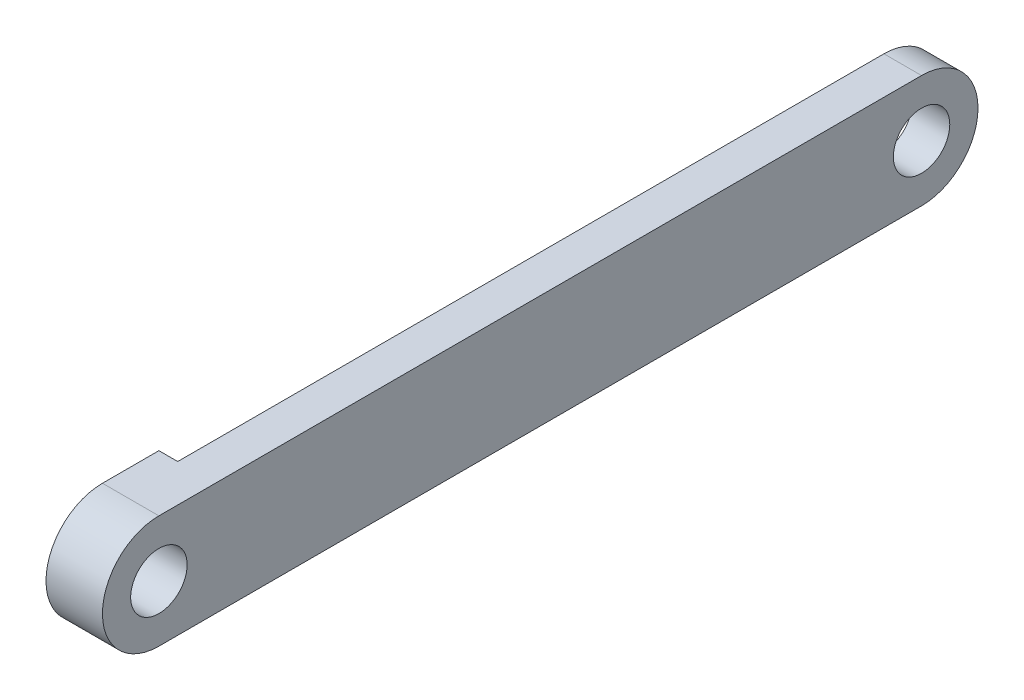
from build123d import *

# Parameters (mm, degrees)
SKETCH1_R           = 1.5
BOSS_EXTRUDE1_DEPTH = 3
SKETCH2_W           = 40.53
SKETCH2_H           = 6
CUT_EXTRUDE1_DEPTH  = 1


with BuildPart() as part:
    # Sketch1 → Boss-Extrude1 (new body)
    with BuildSketch(Plane(origin=(0, 0, 0), x_dir=(0, 0, -1), z_dir=(1, 0, 0))):
        with BuildLine():
            Line((0, -3), (40.53, -3))
            ThreePointArc((40.53, -3), (43.53, 0), (40.53, 3))
            Line((40.53, 3), (0, 3))
            ThreePointArc((0, 3), (-3, 0), (0, -3))
        make_face()
        Circle(SKETCH1_R, mode=Mode.SUBTRACT)
        with Locations((40.53, 0)):
            Circle(SKETCH1_R, mode=Mode.SUBTRACT)
    extrude(amount=BOSS_EXTRUDE1_DEPTH)

    # Sketch2 → Cut-Extrude1 (cut)
    with BuildSketch(Plane.ZY):
        with Locations((-23.265, 0)):
            Rectangle(SKETCH2_W, SKETCH2_H)
    extrude(amount=-CUT_EXTRUDE1_DEPTH, mode=Mode.SUBTRACT)


solid = part.part
